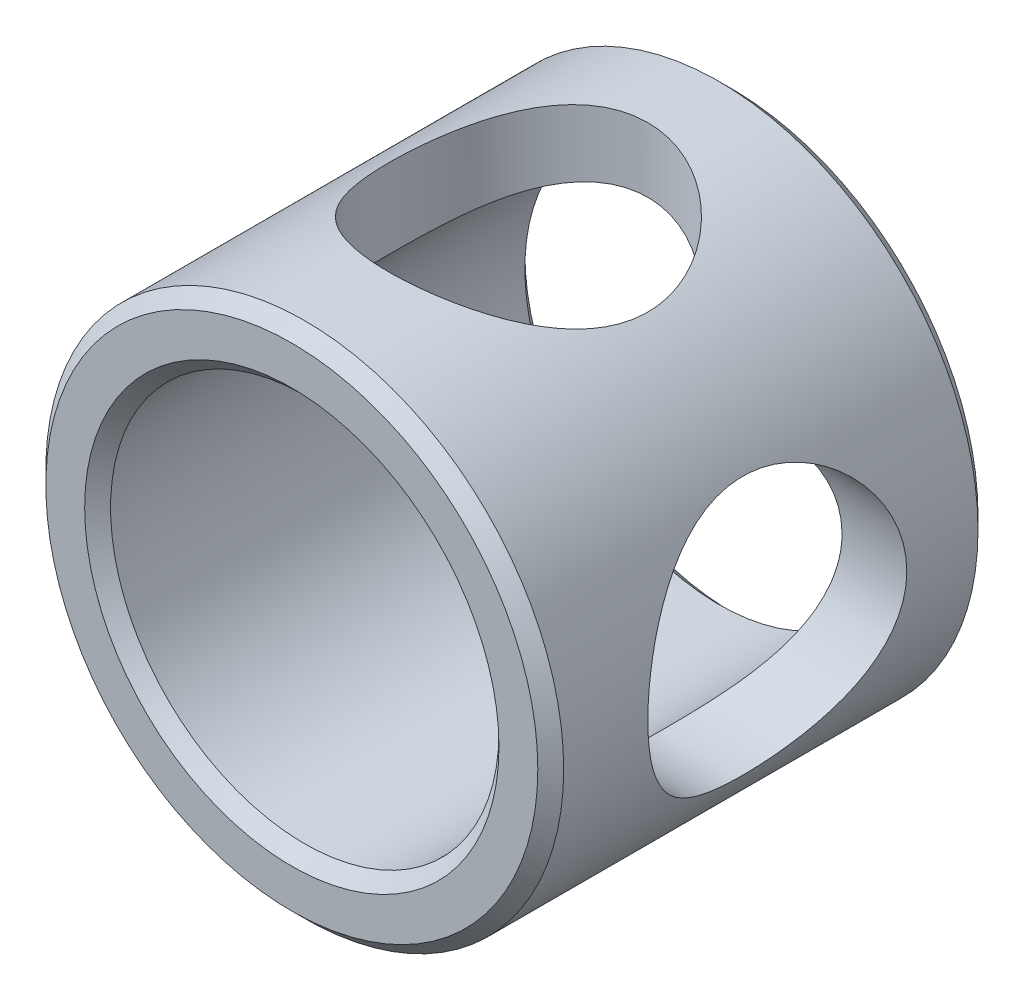
from build123d import *

# Parameters (mm, degrees)
SKETCH1_R               = 4
SKETCH1_R_2             = 3
BOSS_EXTRUDE1_DEPTH     = 6.8
CHAMFER1_SIZE           = 0.2
CUT_EXTRUDE1_REACH      = 13.236
CUT_EXTRUDE1_END_RADIUS = 3
SKETCH2_R               = 2
CIRPATTERN1_COUNT       = 2
CIRPATTERN1_ANGLE       = 90


with BuildPart() as part:
    # Sketch1 → Boss-Extrude1 (new body)
    with BuildSketch(Plane.XY):
        Circle(SKETCH1_R)
        Circle(SKETCH1_R_2, mode=Mode.SUBTRACT)
    extrude(amount=BOSS_EXTRUDE1_DEPTH)

    # Chamfer1
    chamfer1_edges = [part.edges().sort_by_distance(p)[0] for p in [
        (-4, 0, 0),
        (-4, 0, 6.8),
        (-3, 0, 0),
        (-3, 0, 6.8),
    ]]
    chamfer(chamfer1_edges, length=CHAMFER1_SIZE)

    # Cut-Extrude1: up to this cylinder (the profile starts outside it)
    cut_extrude1_end = Plane(origin=(0, 0, 3.3), z_dir=(0, 0, -1)) * Cylinder(CUT_EXTRUDE1_END_RADIUS, 33.472, mode=Mode.PRIVATE)
    # Sketch2 → Cut-Extrude1 (cut, up to the surface)
    with BuildSketch(Plane(origin=(4, 0, 0), x_dir=(0, 0, -1), z_dir=(1, 0, 0)), mode=Mode.PRIVATE) as cut_extrude1_sk1:
        with Locations((-3.3, 0)):
            Circle(SKETCH2_R)
    cut_extrude1_tool1 = extrude(cut_extrude1_sk1.sketch, amount=-CUT_EXTRUDE1_REACH, mode=Mode.PRIVATE) - cut_extrude1_end
    cut_extrude1 = cut_extrude1_tool1.solids().sort_by_distance((4, 0, 3.3))[0]
    add(cut_extrude1, mode=Mode.SUBTRACT)

    # CirPattern1: Cut-Extrude1 ×2 about axis
    cirpattern1_axis = Axis((0, 0, 6.6), (0, 0, 1))
    for i in range(1, CIRPATTERN1_COUNT):
        add(cut_extrude1.rotate(cirpattern1_axis, i * CIRPATTERN1_ANGLE / (CIRPATTERN1_COUNT - 1)), mode=Mode.SUBTRACT)


solid = part.part
